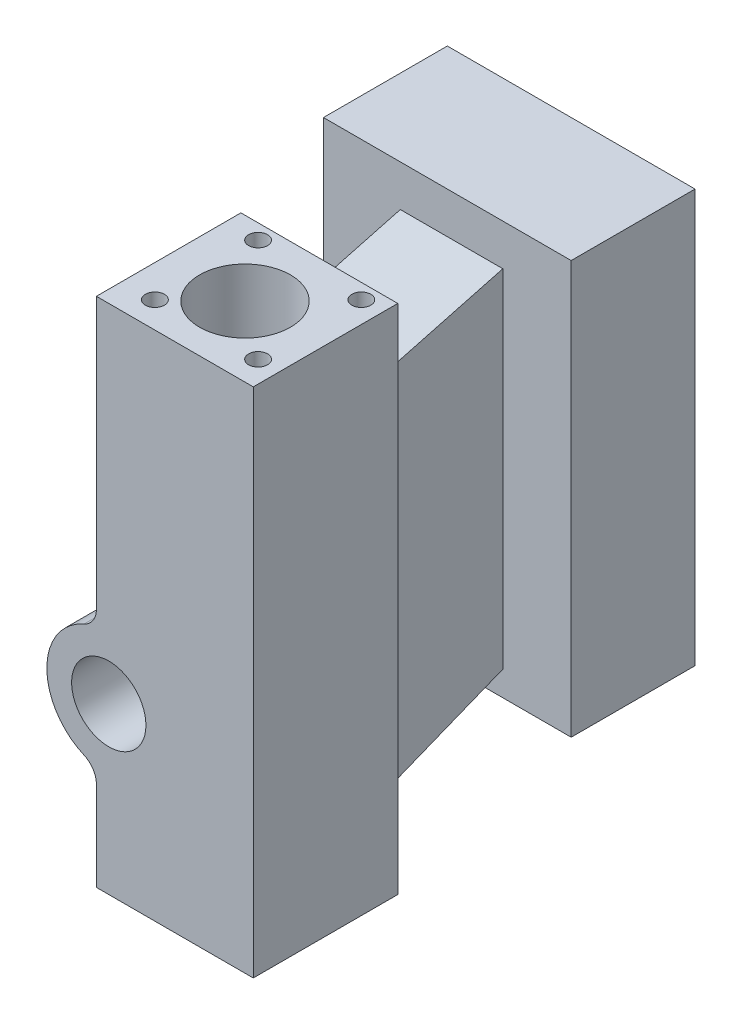
from build123d import *

# Parameters (mm, degrees)
SKETCH1_W            = 38
SKETCH1_H            = 124
BOSS_EXTRUDE1_DEPTH  = 35
SKETCH2_R            = 15
BOSS_EXTRUDE2_DEPTH  = 34
FILLET1_R            = 5
SKETCH3_R            = 11
CUT_EXTRUDE1_DEPTH   = 1000
SKETCH5_W            = 24.830906905
SKETCH5_H            = 111.203932215
BOSS_EXTRUDE3_DEPTH  = 30
SKETCH6_W            = 60
SKETCH6_H            = 100
BOSS_EXTRUDE4_DEPTH  = 30
CUT_EXTRUDE5_DEPTH   = 100
SKETCH10_R           = 7.5
CUT_EXTRUDE6_DEPTH   = 10
SKETCH11_R           = 2.301516645
CUT_EXTRUDE7_DEPTH   = 10
LPATTERN1_COUNT      = 2
LPATTERN1_PITCH      = 25
LPATTERN1_COUNT_DIR2 = 2
LPATTERN1_PITCH_DIR2 = 25
SKETCH4_R            = 9
CUT_EXTRUDE_1_DEPTH  = 17


with BuildPart() as part:
    # Sketch1 → Boss-Extrude1 (new body)
    with BuildSketch(Plane.XY):
        with Locations((-7.18125, -12.690625)):
            Rectangle(SKETCH1_W, SKETCH1_H)
    extrude(amount=BOSS_EXTRUDE1_DEPTH)

    # Sketch2 → Boss-Extrude2 (add)
    with BuildSketch(Plane.XY.offset(35)):
        with Locations((-23.18125, -34.690625)):
            Circle(SKETCH2_R)
    extrude(amount=-BOSS_EXTRUDE2_DEPTH)

    # Fillet1
    fillet1_edges = [part.edges().sort_by_distance(p)[0] for p in [
        (-26.18125, -19.993686543, 18),
        (-26.18125, -49.387563457, 18),
    ]]
    fillet(fillet1_edges, radius=FILLET1_R)

    # Sketch3 → Cut-Extrude1 (cut)
    with BuildSketch(Plane.XZ.offset(74.690625)):
        with Locations((-7.18125, 18)):
            Circle(SKETCH3_R)
    extrude(amount=-CUT_EXTRUDE1_DEPTH, mode=Mode.SUBTRACT)

    # Sketch5 → Boss-Extrude3 (add)
    with BuildSketch(Plane(origin=(0, 0, 0), x_dir=(-1, 0, 0), z_dir=(0, 0, -1))):
        with Locations((5.153648801, -6.911017359)):
            Rectangle(SKETCH5_W, SKETCH5_H)
    extrude(amount=BOSS_EXTRUDE3_DEPTH)

    # Sketch6 → Boss-Extrude4 (add)
    with BuildSketch(Plane(origin=(0, 0, -30), x_dir=(-1, 0, 0), z_dir=(0, 0, -1))):
        with Locations((6.18125, -0.690625)):
            Rectangle(SKETCH6_W, SKETCH6_H)
    extrude(amount=BOSS_EXTRUDE4_DEPTH)

    # Sketch9 → Cut-Extrude5 (cut)
    with BuildSketch(Plane(origin=(7.261804652, 0, 0), x_dir=(0, 0, -1), z_dir=(1, 0, 0))):
        Polygon((0, 52.602660234), (0, 31.309375), (30, 39.309375), (30, 52.602660234), align=None)
        Polygon((0, -56.690625), (0, -66.373805341), (30, -69.28142928), (30, -44.690625), align=None)
    extrude(amount=-CUT_EXTRUDE5_DEPTH, mode=Mode.SUBTRACT)

    # Sketch10 → Cut-Extrude6 (cut)
    with BuildSketch(Plane.ZY.offset(36.18125)):
        with Locations((-45, -15.690625)):
            Circle(SKETCH10_R)
    extrude(amount=-CUT_EXTRUDE6_DEPTH, mode=Mode.SUBTRACT)

    # Sketch11 → Cut-Extrude7 (cut)
    with BuildSketch(Plane(origin=(0, 49.309375, 0), x_dir=(1, 0, 0), z_dir=(0, 1, 0))):
        with Locations((6.624715973, -28.639015413)):
            Circle(SKETCH11_R)
    cut_extrude7 = extrude(amount=-CUT_EXTRUDE7_DEPTH, mode=Mode.SUBTRACT)

    # LPattern1: Cut-Extrude7 2 × 2
    with Locations(*[(-i * LPATTERN1_PITCH, 0, -j * LPATTERN1_PITCH_DIR2) for i in range(LPATTERN1_COUNT) for j in range(LPATTERN1_COUNT_DIR2) if (i, j) != (0, 0)]):
        add(cut_extrude7, mode=Mode.SUBTRACT)

    # Sketch4 → Вырез-Вытянуть1 (cut)
    with BuildSketch(Plane.XY.offset(35)):
        with Locations((-23.18125, -34.690625)):
            Circle(SKETCH4_R)
    extrude(amount=-CUT_EXTRUDE_1_DEPTH, mode=Mode.SUBTRACT)


solid = part.part
